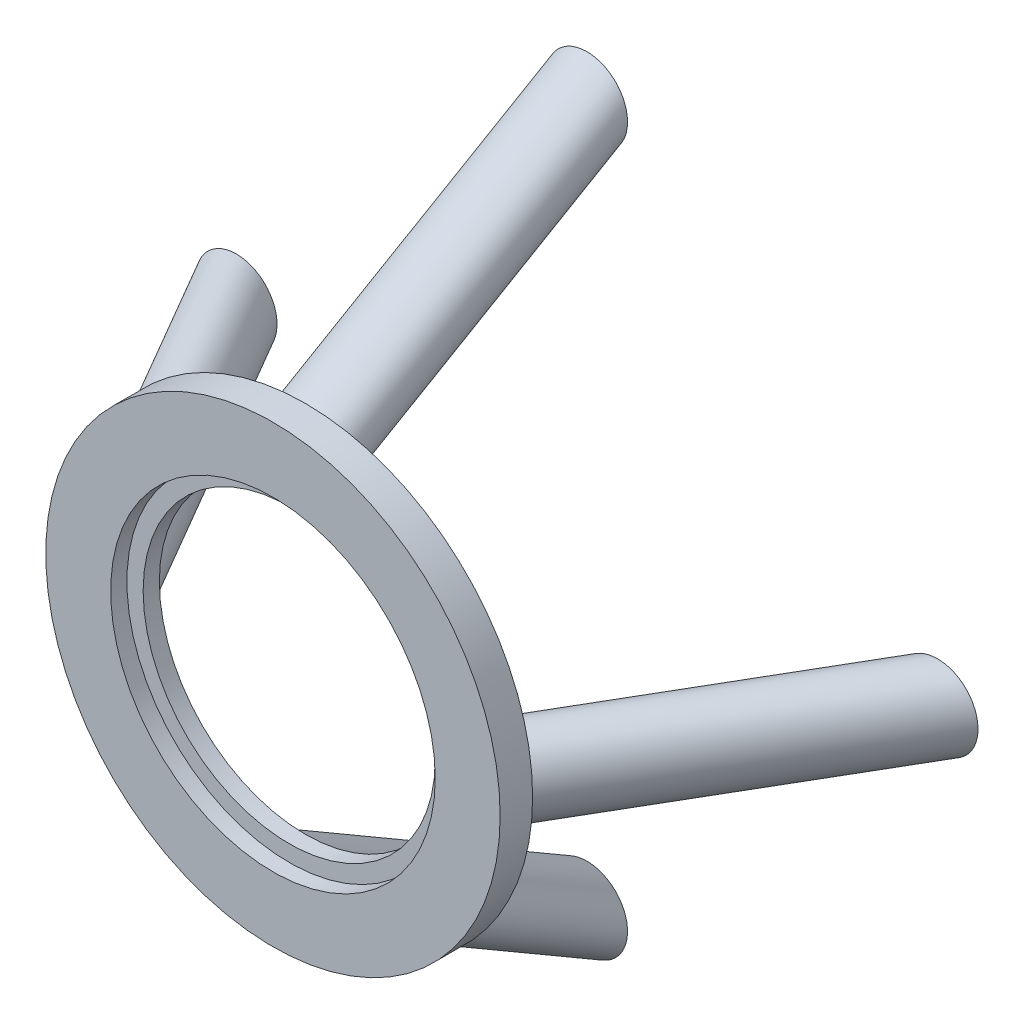
from build123d import *

# Parameters (mm, degrees)
SKETCH1_R           = 70
SKETCH1_R_2         = 50
BOSS_EXTRUDE1_DEPTH = 10
SKETCH1_6_R         = 50
SKETCH1_6_R_2       = 45
BOSS_EXTRUDE3_DEPTH = 5
SKETCH2_R           = 12.5
CIRPATTERN2_COUNT   = 4
CUT_EXTRUDE5_DEPTH  = 2
CUT_EXTRUDE8_START  = -1
CUT_EXTRUDE8_DEPTH  = 1
CIRPATTERN4_COUNT   = 4


with BuildPart() as part:
    # Sketch1 → Boss-Extrude1 (new body)
    with BuildSketch(Plane.XY):
        Circle(SKETCH1_R)
        Circle(SKETCH1_R_2, mode=Mode.SUBTRACT)
    extrude(amount=BOSS_EXTRUDE1_DEPTH)

    # Sketch1_6 → Boss-Extrude3 (add)
    with BuildSketch(Plane.XY):
        Circle(SKETCH1_6_R)
        Circle(SKETCH1_6_R_2, mode=Mode.SUBTRACT)
    extrude(amount=BOSS_EXTRUDE3_DEPTH)

    # Sweep1: sweep along a path in Sketch3
    with BuildLine(Plane(origin=(0, 0, 0), x_dir=(0, 0, -1), z_dir=(1, 0, 0))) as sweep1_path:
        Line((0, -57.5), (86.731949901, -107.982962913))
    # Sketch2 → Sweep1 (sweep)
    with BuildSketch(Plane(origin=(0, 0, 0), x_dir=(-1, 0, 0), z_dir=(0, 0, -1))):
        with Locations((0, -57.5)):
            Circle(SKETCH2_R)
    sweep1 = sweep(path=sweep1_path.line)

    # CirPattern2: Sweep1 ×4 about axis
    cirpattern2_axis = Axis((0, 0, 10), (0, 0, -1))
    for i in range(1, CIRPATTERN2_COUNT):
        add(sweep1.rotate(cirpattern2_axis, i * 360 / CIRPATTERN2_COUNT))

    # Sketch8 → Cut-Extrude5 (cut)
    with BuildSketch(Plane(origin=(0, 0, 0), x_dir=(-1, 0, 0), z_dir=(0, 0, -1))):
        Polygon((-38.890872965, 42.426406871), (-42.426406871, 38.890872965), (-38.890872965, 35.355339059), (-35.355339059, 38.890872965), align=None)
    cut_extrude5 = extrude(amount=-CUT_EXTRUDE5_DEPTH, mode=Mode.SUBTRACT)

    # Sketch8_6 → Cut-Extrude8 (cut)
    with BuildSketch(Plane(origin=(0, 0, 0), x_dir=(-1, 0, 0), z_dir=(0, 0, -1)).offset(CUT_EXTRUDE8_START)):
        Polygon((-45.961940777, 42.426406871), (-42.426406871, 38.890872965), (-38.890872965, 42.426406871), (-42.426406871, 45.961940777), align=None)
    cut_extrude8 = extrude(amount=-CUT_EXTRUDE8_DEPTH, mode=Mode.SUBTRACT)

    # CirPattern4: Cut-Extrude5, Cut-Extrude8 ×4 about axis
    cirpattern4_axis = Axis((0, 0, 10), (0, 0, -1))
    add([cut_extrude5.rotate(cirpattern4_axis, i * 360 / CIRPATTERN4_COUNT) for i in range(1, CIRPATTERN4_COUNT)], mode=Mode.SUBTRACT)
    add([cut_extrude8.rotate(cirpattern4_axis, i * 360 / CIRPATTERN4_COUNT) for i in range(1, CIRPATTERN4_COUNT)], mode=Mode.SUBTRACT)


solid = part.part
